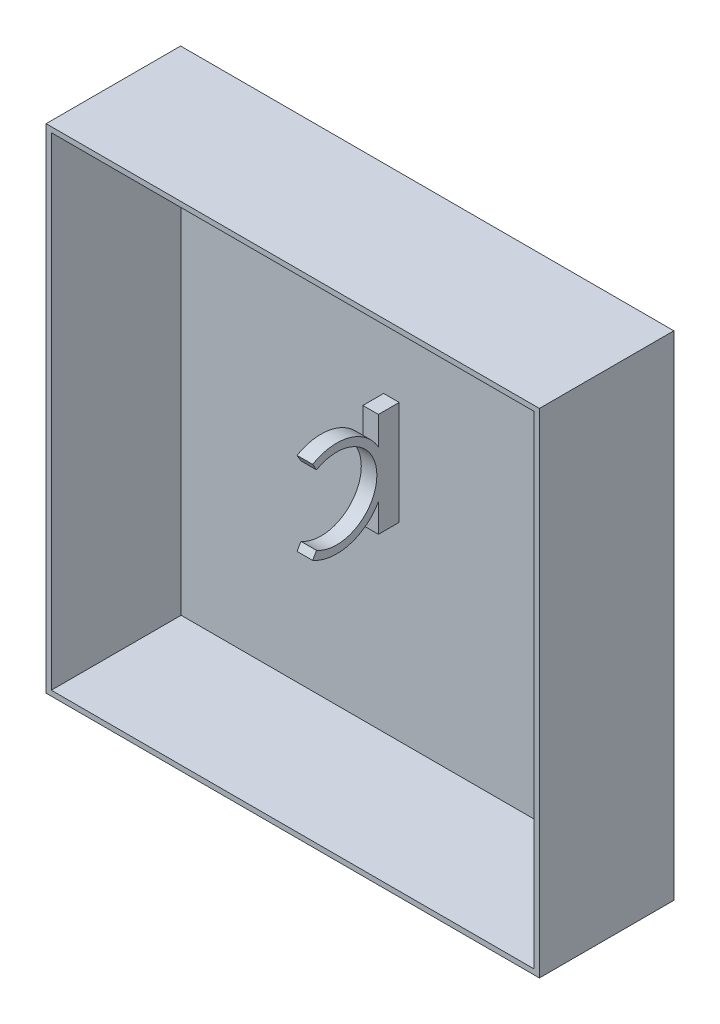
from build123d import *

# Parameters (mm, degrees)
CROQUIS1_W              = 95
CROQUIS1_H              = 95
SALIENTE_EXTRUIR1_DEPTH = 0.9
CROQUIS2_W              = 95
CROQUIS2_H              = 95
CROQUIS2_W_2            = 93
CROQUIS2_H_2            = 93
SALIENTE_EXTRUIR2_DEPTH = 25
CROQUIS3_W              = 3
CROQUIS3_H              = 20
SALIENTE_EXTRUIR3_DEPTH = 4
SALIENTE_EXTRUIR4_START = -3
SALIENTE_EXTRUIR4_DEPTH = 3


with BuildPart() as part:
    # Croquis1 → Saliente-Extruir1 (new body)
    with BuildSketch(Plane.XY):
        Rectangle(CROQUIS1_W, CROQUIS1_H)
        with BuildLine():
            Line((-44.5, 39.976525822), (-44.5, 34.976525822))
            ThreePointArc((-44.5, 34.976525822), (-42.5, 30.976525822), (-40.5, 34.976525822))
            Line((-40.5, 34.976525822), (-40.5, 39.976525822))
            ThreePointArc((-40.5, 39.976525822), (-42.5, 41.976525822), (-44.5, 39.976525822))
        make_face(mode=Mode.SUBTRACT)
        with BuildLine():
            Line((40.5, 39.976525822), (40.5, 34.976525822))
            ThreePointArc((40.5, 34.976525822), (42.5, 30.976525822), (44.5, 34.976525822))
            Line((44.5, 34.976525822), (44.5, 39.976525822))
            ThreePointArc((44.5, 39.976525822), (42.5, 41.976525822), (40.5, 39.976525822))
        make_face(mode=Mode.SUBTRACT)
    extrude(amount=SALIENTE_EXTRUIR1_DEPTH)

    # Croquis2 → Saliente-Extruir2 (add)
    with BuildSketch(Plane.XY.offset(0.9)):
        Rectangle(CROQUIS2_W, CROQUIS2_H)
        Rectangle(CROQUIS2_W_2, CROQUIS2_H_2, mode=Mode.SUBTRACT)
    extrude(amount=SALIENTE_EXTRUIR2_DEPTH)

    # Croquis3 → Saliente-Extruir3 (add)
    with BuildSketch(Plane.XY.offset(0.9)):
        with Locations((-6, 0)):
            Rectangle(CROQUIS3_W, CROQUIS3_H)
    extrude(amount=SALIENTE_EXTRUIR3_DEPTH)

    # Croquis4 → Saliente-Extruir4 (add)
    with BuildSketch(Plane.ZY.offset(7.5).offset(SALIENTE_EXTRUIR4_START)):
        with BuildLine():
            Line((17.575, 8.010734985), (16.825, 6.711696879))
            ThreePointArc((16.825, 6.711696879), (5.2, 0), (16.825, -6.711696879))
            Line((16.825, -6.711696879), (17.575, -8.010734985))
            ThreePointArc((17.575, -8.010734985), (10.517735249, -8.924493721), (4.9, -4.5563143))
            Line((4.9, -4.5563143), (4.9, 4.5563143))
            ThreePointArc((4.9, 4.5563143), (10.517735249, 8.924493721), (17.575, 8.010734985))
        make_face()
    extrude(amount=SALIENTE_EXTRUIR4_DEPTH)


solid = part.part
